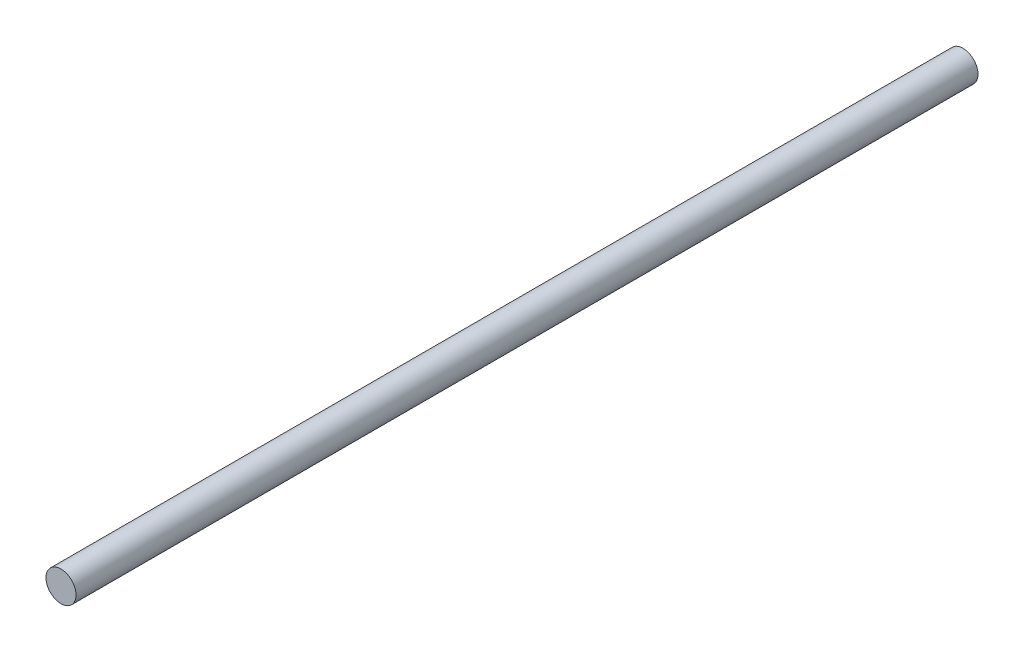
from build123d import *

# Parameters (mm, degrees)
SKETCH1_R           = 2.5
BOSS_EXTRUDE2_DEPTH = 150


with BuildPart() as part:
    # Sketch1 → Boss-Extrude2 (new body)
    with BuildSketch(Plane.XY):
        with Locations((2.854893517, 19.474452204)):
            Circle(SKETCH1_R)
    extrude(amount=BOSS_EXTRUDE2_DEPTH)


solid = part.part
